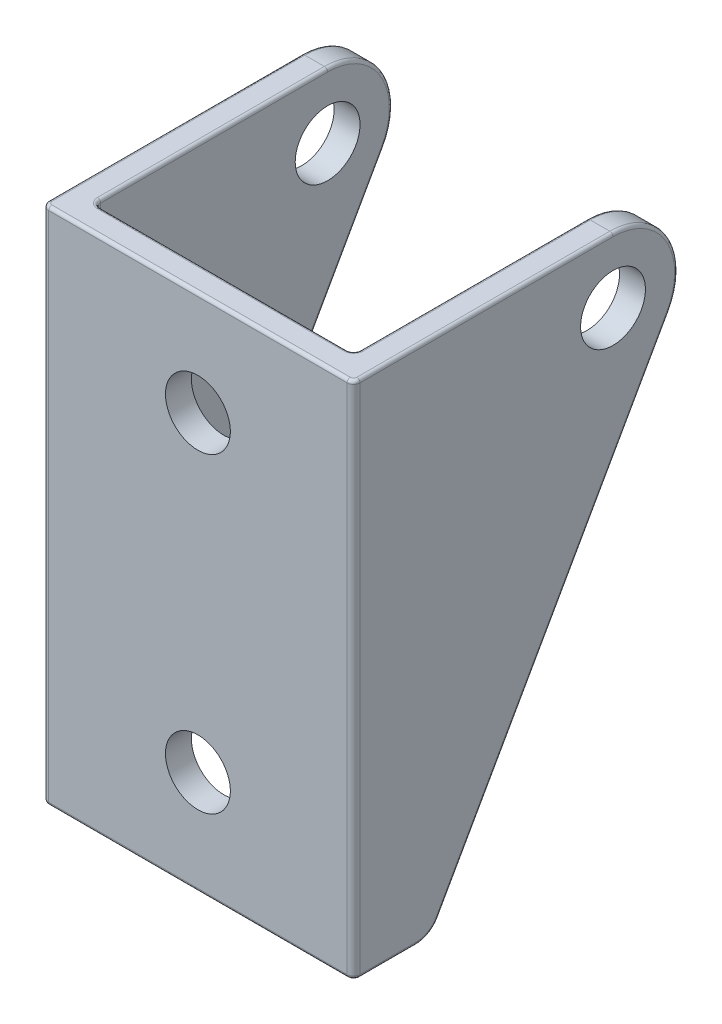
from build123d import *

# Parameters (mm, degrees)
BOSS_EXTRUDE1_DEPTH = 40
SKETCH2_OUTSIDE_W   = 37.584
SKETCH2_OUTSIDE_H   = 52.584
CUT_EXTRUDE1_DEPTH  = 30
FILLET1_R           = 0.25
SKETCH3_R           = 2.5
CUT_EXTRUDE2_DEPTH  = 40
SKETCH4_R           = 2.5
CUT_EXTRUDE3_DEPTH  = 30


with BuildPart() as part:
    # Sketch1 → Boss-Extrude1 (new body)
    with BuildSketch(Plane(origin=(0, 0, 0), x_dir=(1, 0, 0), z_dir=(0, 1, 0))):
        with BuildLine():
            Line((12, -1.5), (12, 23))
            Line((12, 23), (10, 23))
            Line((10, 23), (10, 0.5))
            ThreePointArc((10, 0.5), (9.853553391, 0.146446609), (9.5, 0))
            Line((9.5, 0), (-9.5, 0))
            ThreePointArc((-9.5, 0), (-9.853553391, 0.146446609), (-10, 0.5))
            Line((-10, 0.5), (-10, 23))
            Line((-10, 23), (-12, 23))
            Line((-12, 23), (-12, -1.5))
            ThreePointArc((-12, -1.5), (-11.853553391, -1.853553391), (-11.5, -2))
            Line((-11.5, -2), (11.5, -2))
            ThreePointArc((11.5, -2), (11.853553391, -1.853553391), (12, -1.5))
        make_face()
    extrude(amount=BOSS_EXTRUDE1_DEPTH)

    # Sketch2 outside → Cut-Extrude1 (cut)
    with BuildSketch(Plane.ZY.offset(12)):
        with Locations((-10.5, 20)):
            Rectangle(SKETCH2_OUTSIDE_W, SKETCH2_OUTSIDE_H)
        with BuildLine():
            Line((-22.35505953, 32.543690474), (-4.573869643, 1.017476189))
            ThreePointArc((-4.573869643, 1.017476189), (-3.840546078, 0.273001502), (-2.831845831, 0))
            Line((-2.831845831, 0), (2, 0))
            Line((2, 0), (2, 40))
            Line((2, 40), (-18, 40))
            ThreePointArc((-18, 40), (-22.317496244, 37.521750619), (-22.35505953, 32.543690474))
        make_face(mode=Mode.SUBTRACT)
    extrude(amount=-CUT_EXTRUDE1_DEPTH, mode=Mode.SUBTRACT)

    # Fillet1
    fillet1_edges = [part.edges().sort_by_distance(p)[0] for p in [
        (-10, 0, -1.665922915),
        (-9.853553391, 0, -0.146446609),
        (-11.853553391, 40, 1.853553391),
        (0, 0, 0),
        (9.853553391, 0, -0.146446609),
        (12, 0, -0.665922915),
        (11.853553391, 0, 1.853553391),
        (0, 0, 2),
        (-11.853553391, 0, 1.853553391),
        (0, 40, 2),
        (11.853553391, 40, 1.853553391),
        (12, 40, -8.25),
        (10, 0, -1.665922915),
        (9.853553391, 40, -0.146446609),
        (-12, 0, -0.665922915),
        (-12, 40, -8.25),
        (10, 40, -9.25),
        (0, 40, 0),
        (-10, 16.780583332, -13.464464586),
        (-9.853553391, 40, -0.146446609),
        (-10, 40, -9.25),
        (12, 16.780583332, -13.464464586),
        (-12, 16.780583332, -13.464464586),
        (-12, 37.521750619, -22.317496244),
        (12, 37.521750619, -22.317496244),
        (12, 0.273001502, -3.840546078),
        (-12, 0.273001502, -3.840546078),
        (10, 37.521750619, -22.317496244),
        (-10, 37.521750619, -22.317496244),
        (10, 0.273001502, -3.840546078),
        (-10, 0.273001502, -3.840546078),
        (10, 16.780583332, -13.464464586),
    ]]
    fillet(fillet1_edges, radius=FILLET1_R)

    # Sketch3 → Cut-Extrude2 (cut)
    with BuildSketch(Plane.ZY.offset(12)):
        with Locations((-18, 35)):
            Circle(SKETCH3_R)
    extrude(amount=-CUT_EXTRUDE2_DEPTH, mode=Mode.SUBTRACT)

    # Sketch4 → Cut-Extrude3 (cut)
    with BuildSketch(Plane(origin=(0, 0, 0), x_dir=(-1, 0, 0), z_dir=(0, 0, -1))):
        with Locations((0, 32)):
            Circle(SKETCH4_R)
        with Locations((0, 8)):
            Circle(SKETCH4_R)
    extrude(amount=-CUT_EXTRUDE3_DEPTH, mode=Mode.SUBTRACT)


solid = part.part
